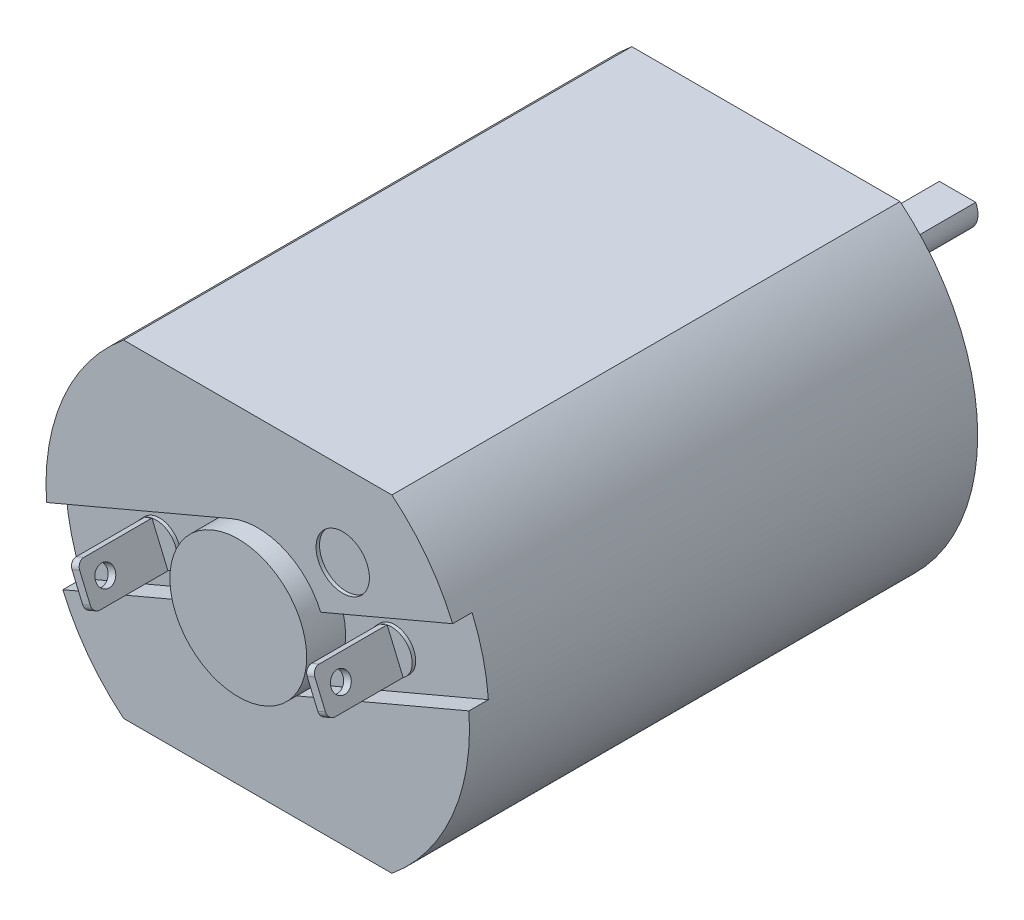
from build123d import *

# Parameters (mm, degrees)
EXTRUDE1_DEPTH     = 18.5928
SKETCH2_R          = 2.3495
EXTRUDE2_DEPTH     = 1.524
SKETCH3_R          = 0.74803
EXTRUDE3_DEPTH     = 5.4864
SKETCH4_R          = 2.5019
EXTRUDE4_DEPTH     = 0.7112
SKETCH6_R          = 0.806604734
SKETCH6_R_2        = 0.8001
CUT_EXTRUDE1_DEPTH = 2
CUT_EXTRUDE2_DEPTH = 0.7112
CUT_EXTRUDE3_DEPTH = 0.7112
EXTRUDE5_DEPTH     = 2.8702
FILLET1_R          = 0.254
SKETCH11_R         = 0.3556
CUT_EXTRUDE4_DEPTH = 0.381
SKETCH12_R         = 0.3556
CUT_EXTRUDE5_DEPTH = 0.381
SKETCH13_R         = 0.764641256
EXTRUDE6_DEPTH     = 0.127
SKETCH14_R         = 0.976393175
EXTRUDE7_DEPTH     = 0.127
EXTRUDE8_DEPTH     = 5.207


with BuildPart() as part:
    # Sketch1 → Extrude1 (new body)
    with BuildSketch(Plane.XY):
        with BuildLine():
            Line((-4.907461425, 5.9944), (4.907461425, 5.9944))
            ThreePointArc((4.907461425, 5.9944), (7.747, 0), (4.907461425, -5.9944))
            Line((4.907461425, -5.9944), (-4.907461425, -5.9944))
            ThreePointArc((-4.907461425, -5.9944), (-7.747, 0), (-4.907461425, 5.9944))
        make_face()
    extrude(amount=EXTRUDE1_DEPTH)

    # Sketch2 → Extrude2 (add)
    with BuildSketch(Plane(origin=(0, 0, 0), x_dir=(-1, 0, 0), z_dir=(0, 0, -1))):
        Circle(SKETCH2_R)
    extrude(amount=EXTRUDE2_DEPTH)

    # Sketch3 → Extrude3 (add)
    with BuildSketch(Plane(origin=(0, 0, -1.524), x_dir=(-1, 0, 0), z_dir=(0, 0, -1))):
        Circle(SKETCH3_R)
    extrude(amount=EXTRUDE3_DEPTH)

    # Sketch4 → Extrude4 (add)
    with BuildSketch(Plane.XY.offset(18.5928)):
        Circle(SKETCH4_R)
    extrude(amount=EXTRUDE4_DEPTH)

    # Sketch6 → Cut-Extrude1 (cut)
    with BuildSketch(Plane(origin=(0, 0, 0), x_dir=(-1, 0, 0), z_dir=(0, 0, -1))):
        with Locations((4.333417915, 2.5019)):
            Circle(SKETCH6_R)
        with Locations((-4.333417915, -2.5019)):
            Circle(SKETCH6_R_2)
    extrude(amount=-CUT_EXTRUDE1_DEPTH, mode=Mode.SUBTRACT)

    # Sketch8 → Cut-Extrude2 (cut)
    with BuildSketch(Plane.XY.offset(18.5928)):
        with BuildLine():
            Line((2.303011093, 0.97757021), (7.222442902, 3.065745123))
            Line((7.222442902, 3.065745123), (8.200013112, 0.76273403))
            Line((8.200013112, 0.76273403), (0.97757021, -2.303011093))
            ThreePointArc((0.97757021, -2.303011093), (2.319721286, -0.937228236), (2.303011093, 0.97757021))
        make_face()
    extrude(amount=-CUT_EXTRUDE2_DEPTH, mode=Mode.SUBTRACT)

    # Sketch9 → Cut-Extrude3 (cut)
    with BuildSketch(Plane.XY.offset(18.5928)):
        with BuildLine():
            Line((-2.303011093, -0.97757021), (-8.41785865, -3.573169003))
            Line((-8.41785865, -3.573169003), (-9.39542886, -1.27015791))
            Line((-9.39542886, -1.27015791), (-0.97757021, 2.303011093))
            ThreePointArc((-0.97757021, 2.303011093), (-2.319721286, 0.937228236), (-2.303011093, -0.97757021))
        make_face()
    extrude(amount=-CUT_EXTRUDE3_DEPTH, mode=Mode.SUBTRACT)

    # Sketch10 → Extrude5 (add)
    with BuildSketch(Plane.XY.offset(17.8816)):
        Polygon((-4.735400216, 0.169832597), (-4.149850547, -1.209635977), (-3.869280668, -1.090541129), (-4.454830337, 0.288927445), align=None)
        Polygon((3.869280668, 1.090541129), (4.149850547, 1.209635977), (4.735400216, -0.169832597), (4.454830337, -0.288927445), align=None)
    extrude(amount=EXTRUDE5_DEPTH)

    # Fillet1
    fillet1_edges = [part.edges().sort_by_distance(p)[0] for p in [
        (-4.595115277, 0.229380021, 20.7518),
        (-4.009565608, -1.150088553, 20.7518),
        (4.595115277, -0.229380021, 20.7518),
        (4.009565608, 1.150088553, 20.7518),
    ]]
    fillet(fillet1_edges, radius=FILLET1_R)

    # Sketch11 → Cut-Extrude4 (cut)
    with BuildSketch(Plane(origin=(-3.951359134, -1.677252442, 0), x_dir=(0, 0, 1), z_dir=(-0.920504853, -0.390731128, 0))):
        with Locations((20.001394918, 1.27)):
            Circle(SKETCH11_R)
    extrude(amount=-CUT_EXTRUDE4_DEPTH, mode=Mode.SUBTRACT)

    # Sketch12 → Cut-Extrude5 (cut)
    with BuildSketch(Plane(origin=(3.951359134, 1.677252442, 0), x_dir=(0, 0, -1), z_dir=(0.920504853, 0.390731128, 0))):
        with Locations((-19.9898, -1.2446)):
            Circle(SKETCH12_R)
    extrude(amount=-CUT_EXTRUDE5_DEPTH, mode=Mode.SUBTRACT)

    # Sketch13 → Extrude6 (add)
    with BuildSketch(Plane.XY.offset(17.8816)):
        with Locations((4.302340442, 0.460354266)):
            Circle(SKETCH13_R)
        with Locations((-4.302340442, -0.460354266)):
            Circle(SKETCH13_R)
    extrude(amount=EXTRUDE6_DEPTH)

    # Sketch14 → Extrude7 (cut)
    with BuildSketch(Plane.XY.offset(18.5928)):
        with Locations((3.109494983, 2.955380071)):
            Circle(SKETCH14_R)
    extrude(amount=-EXTRUDE7_DEPTH, mode=Mode.SUBTRACT)

    # Sketch15 → Extrude8 (cut)
    with BuildSketch(Plane(origin=(0, 0, -7.0104), x_dir=(-1, 0, 0), z_dir=(0, 0, -1))):
        with BuildLine():
            Line((-0.664807093, 0.3429), (0.664807093, 0.3429))
            ThreePointArc((0.664807093, 0.3429), (0, 0.74803), (-0.664807093, 0.3429))
        make_face()
    extrude(amount=-EXTRUDE8_DEPTH, mode=Mode.SUBTRACT)


solid = part.part
